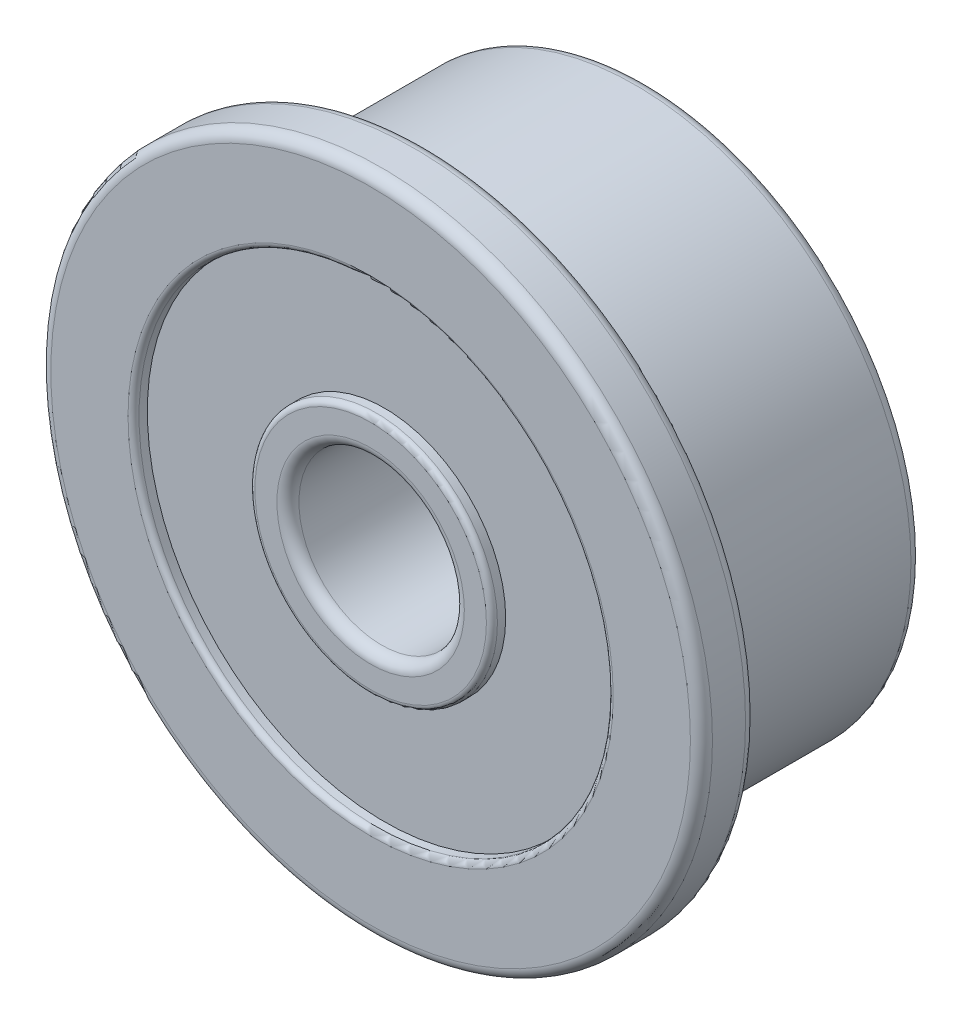
from build123d import *

# Parameters (mm, degrees)
SKETCH1_R           = 5
SKETCH1_R_2         = 1.5
BOSS_EXTRUDE1_DEPTH = 4
SKETCH2_R           = 6
SKETCH2_R_2         = 1.5
BOSS_EXTRUDE2_DEPTH = 1
FILLET1_R           = 0.2
SKETCH3_R           = 4.3
SKETCH3_R_2         = 2.2
CUT_EXTRUDE1_DEPTH  = 0.25
SKETCH4_R           = 4.3
SKETCH4_R_2         = 2.2
CUT_EXTRUDE2_DEPTH  = 0.25
FILLET2_R           = 0.1


with BuildPart() as part:
    # Sketch1 → Boss-Extrude1 (new body)
    with BuildSketch(Plane.XY):
        Circle(SKETCH1_R)
        Circle(SKETCH1_R_2, mode=Mode.SUBTRACT)
    extrude(amount=BOSS_EXTRUDE1_DEPTH)

    # Sketch2 → Boss-Extrude2 (add)
    with BuildSketch(Plane.XY.offset(4)):
        Circle(SKETCH2_R)
        Circle(SKETCH2_R_2, mode=Mode.SUBTRACT)
    extrude(amount=BOSS_EXTRUDE2_DEPTH)

    # Fillet1
    fillet1_edges = [part.edges().sort_by_distance(p)[0] for p in [
        (-6, 0, 4),
        (-1.5, 0, 5),
        (-5, 0, 0),
        (-1.5, 0, 0),
        (-6, 0, 5),
    ]]
    fillet(fillet1_edges, radius=FILLET1_R)

    # Sketch3 → Cut-Extrude1 (cut)
    with BuildSketch(Plane(origin=(0, 0, 0), x_dir=(-1, 0, 0), z_dir=(0, 0, -1))):
        Circle(SKETCH3_R)
        Circle(SKETCH3_R_2, mode=Mode.SUBTRACT)
    extrude(amount=-CUT_EXTRUDE1_DEPTH, mode=Mode.SUBTRACT)

    # Sketch4 → Cut-Extrude2 (cut)
    with BuildSketch(Plane.XY.offset(5)):
        Circle(SKETCH4_R)
        Circle(SKETCH4_R_2, mode=Mode.SUBTRACT)
    extrude(amount=-CUT_EXTRUDE2_DEPTH, mode=Mode.SUBTRACT)

    # Fillet2
    fillet2_edges = [part.edges().sort_by_distance(p)[0] for p in [
        (4.3, 0, 0),
        (2.2, 0, 0),
        (-4.3, 0, 5),
        (-2.2, 0, 5),
    ]]
    fillet(fillet2_edges, radius=FILLET2_R)


solid = part.part
